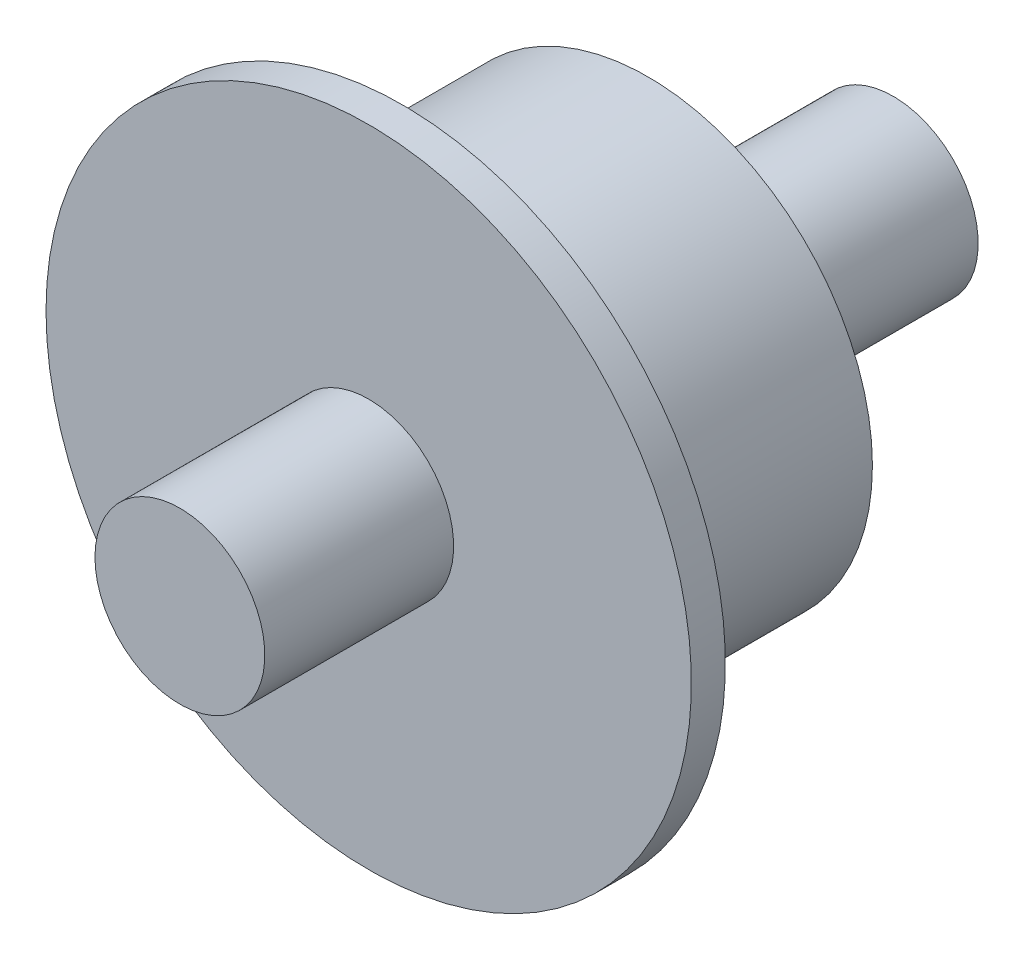
from build123d import *


with BuildPart() as part:
    # Sketch1 → Revolve1 (revolve)
    with BuildSketch(Plane(origin=(0, 0, 0), x_dir=(1, 0, 0), z_dir=(0, 1, 0))):
        Polygon((-5, 18.86557377), (0, 18.86557377), (0, -23.13442623), (-5, -23.13442623), (-5, -12.016393475), (-19, -12.016393475), (-19, -10.016393411), (-13.216262453, -10.016393411), (-13.216262453, 4.42459018), (-5, 4.42459018), align=None)
    revolve(axis=Axis((0, 0, -18.86557377), (0, 0, 1)))


solid = part.part
